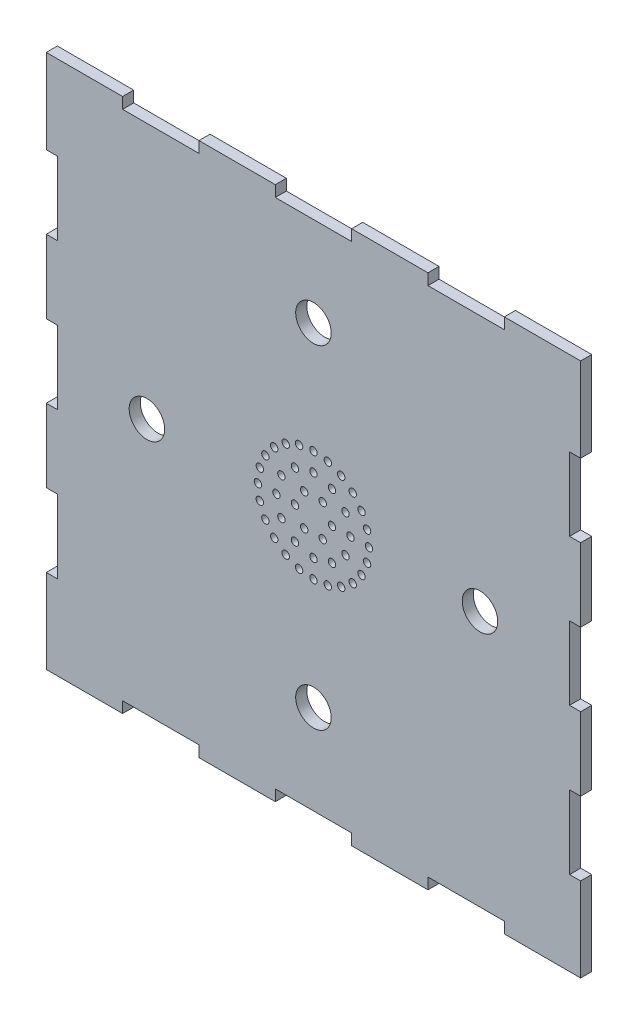
from build123d import *

# Parameters (mm, degrees)
SKETCH1_W           = 144.4
SKETCH1_H           = 144.4
BOSS_EXTRUDE1_DEPTH = 3
SKETCH2_W           = 20.628571
SKETCH2_H           = 3
SKETCH2_W_2         = 3
SKETCH2_H_2         = 19.771429
SKETCH2_H_3         = 19.83347722
SKETCH2_H_4         = 19.833479362
SKETCH2_H_5         = 19.771431142
CUT_EXTRUDE1_DEPTH  = 4
SKETCH3_R           = 1
CUT_EXTRUDE2_DEPTH  = 4
SKETCH4_R           = 4.8
CUT_EXTRUDE3_DEPTH  = 4


with BuildPart() as part:
    # Sketch1 → Boss-Extrude1 (new body)
    with BuildSketch(Plane.XY):
        Rectangle(SKETCH1_W, SKETCH1_H)
    extrude(amount=BOSS_EXTRUDE1_DEPTH)

    # Sketch2 → Cut-Extrude1 (cut, through all)
    with BuildSketch(Plane(origin=(0, 0, 0), x_dir=(-1, 0, 0), z_dir=(0, 0, -1))):
        with Locations((-41.257140929, 70.7)):
            Rectangle(SKETCH2_W, SKETCH2_H)
        with Locations((1.071e-06, 70.7)):
            Rectangle(SKETCH2_W, SKETCH2_H)
        with Locations((41.257143071, 70.7)):
            Rectangle(SKETCH2_W, SKETCH2_H)
        with Locations((70.7, 39.542856929)):
            Rectangle(SKETCH2_W_2, SKETCH2_H_2)
        with Locations((70.7, -1.071e-06)):
            Rectangle(SKETCH2_W_2, SKETCH2_H_2)
        with Locations((70.7, -39.573883181)):
            Rectangle(SKETCH2_W_2, SKETCH2_H_3)
        with Locations((41.257143071, -70.7)):
            Rectangle(SKETCH2_W, SKETCH2_H)
        with Locations((1.071e-06, -70.7)):
            Rectangle(SKETCH2_W, SKETCH2_H)
        with Locations((-41.257140929, -70.7)):
            Rectangle(SKETCH2_W, SKETCH2_H)
        with Locations((-70.7, -39.57388211)):
            Rectangle(SKETCH2_W_2, SKETCH2_H_4)
        with Locations((-70.7, 0)):
            Rectangle(SKETCH2_W_2, SKETCH2_H_5)
        with Locations((-70.7, 39.542858)):
            Rectangle(SKETCH2_W_2, SKETCH2_H_5)
    extrude(amount=-CUT_EXTRUDE1_DEPTH, mode=Mode.SUBTRACT)

    # Sketch3 → Cut-Extrude2 (cut, through all)
    with BuildSketch(Plane(origin=(0, 0, 0), x_dir=(-1, 0, 0), z_dir=(0, 0, -1))):
        with Locations((5, 0)):
            Circle(SKETCH3_R)
        with Locations((2.5, -4.330127019)):
            Circle(SKETCH3_R)
        with Locations((-2.5, -4.330127019)):
            Circle(SKETCH3_R)
        with Locations((-5, 0)):
            Circle(SKETCH3_R)
        with Locations((-2.5, 4.330127019)):
            Circle(SKETCH3_R)
        with Locations((2.5, 4.330127019)):
            Circle(SKETCH3_R)
        with Locations((10, 0)):
            Circle(SKETCH3_R)
        with Locations((8.660254038, -5)):
            Circle(SKETCH3_R)
        with Locations((5, -8.660254038)):
            Circle(SKETCH3_R)
        with Locations((0, -10)):
            Circle(SKETCH3_R)
        with Locations((-5, -8.660254038)):
            Circle(SKETCH3_R)
        with Locations((-8.660254038, -5)):
            Circle(SKETCH3_R)
        with Locations((-10, 0)):
            Circle(SKETCH3_R)
        with Locations((-8.660254038, 5)):
            Circle(SKETCH3_R)
        with Locations((-5, 8.660254038)):
            Circle(SKETCH3_R)
        with Locations((0, 10)):
            Circle(SKETCH3_R)
        with Locations((5, 8.660254038)):
            Circle(SKETCH3_R)
        with Locations((8.660254038, 5)):
            Circle(SKETCH3_R)
        with Locations((15, 0)):
            Circle(SKETCH3_R)
        with Locations((14.488887394, -3.882285677)):
            Circle(SKETCH3_R)
        with Locations((12.990381057, -7.5)):
            Circle(SKETCH3_R)
        with Locations((10.606601718, -10.606601718)):
            Circle(SKETCH3_R)
        with Locations((7.5, -12.990381057)):
            Circle(SKETCH3_R)
        with Locations((3.882285677, -14.488887394)):
            Circle(SKETCH3_R)
        with Locations((0, -15)):
            Circle(SKETCH3_R)
        with Locations((-3.882285677, -14.488887394)):
            Circle(SKETCH3_R)
        with Locations((-7.5, -12.990381057)):
            Circle(SKETCH3_R)
        with Locations((-10.606601718, -10.606601718)):
            Circle(SKETCH3_R)
        with Locations((-12.990381057, -7.5)):
            Circle(SKETCH3_R)
        with Locations((-14.488887394, -3.882285677)):
            Circle(SKETCH3_R)
        with Locations((-15, 0)):
            Circle(SKETCH3_R)
        with Locations((-14.488887394, 3.882285677)):
            Circle(SKETCH3_R)
        with Locations((-12.990381057, 7.5)):
            Circle(SKETCH3_R)
        with Locations((-10.606601718, 10.606601718)):
            Circle(SKETCH3_R)
        with Locations((-7.5, 12.990381057)):
            Circle(SKETCH3_R)
        with Locations((-3.882285677, 14.488887394)):
            Circle(SKETCH3_R)
        with Locations((0, 15)):
            Circle(SKETCH3_R)
        with Locations((3.882285677, 14.488887394)):
            Circle(SKETCH3_R)
        with Locations((7.5, 12.990381057)):
            Circle(SKETCH3_R)
        with Locations((10.606601718, 10.606601718)):
            Circle(SKETCH3_R)
        with Locations((12.990381057, 7.5)):
            Circle(SKETCH3_R)
        with Locations((14.488887394, 3.882285677)):
            Circle(SKETCH3_R)
    extrude(amount=-CUT_EXTRUDE2_DEPTH, mode=Mode.SUBTRACT)

    # Sketch4 → Cut-Extrude3 (cut, through all)
    with BuildSketch(Plane.XY.offset(3)):
        with Locations((0, 45)):
            Circle(SKETCH4_R)
        with Locations((45, 0)):
            Circle(SKETCH4_R)
        with Locations((0, -45)):
            Circle(SKETCH4_R)
        with Locations((-45, 0)):
            Circle(SKETCH4_R)
    extrude(amount=-CUT_EXTRUDE3_DEPTH, mode=Mode.SUBTRACT)


solid = part.part
